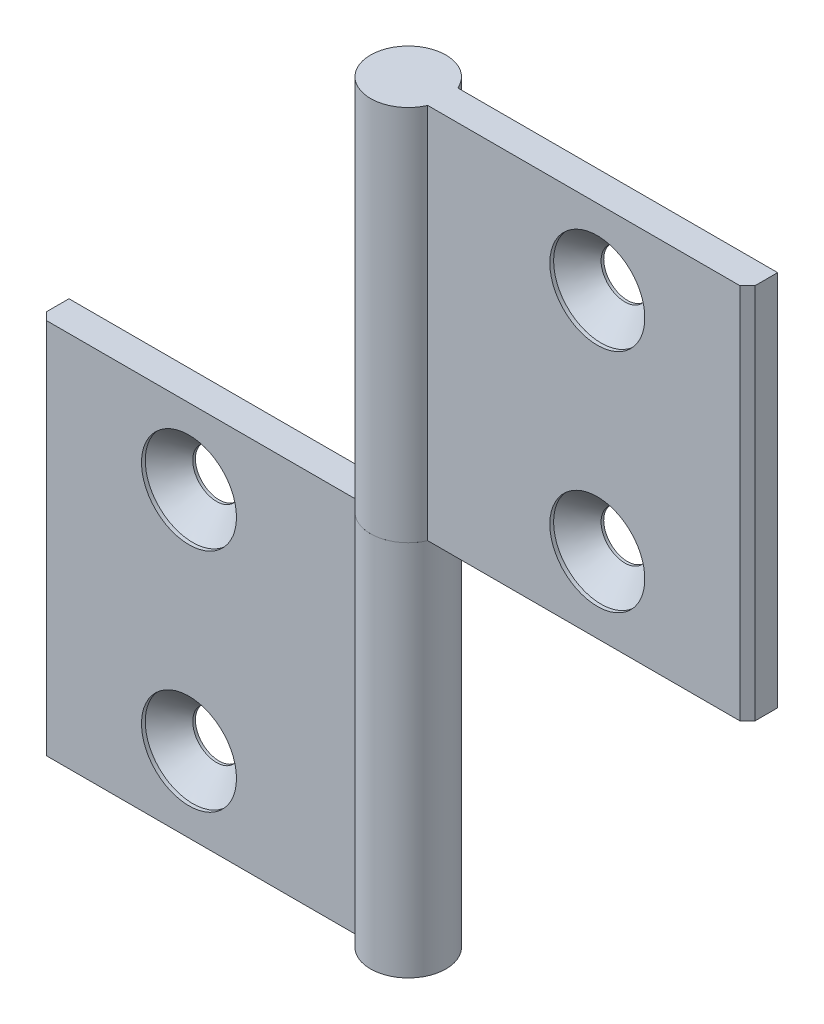
from build123d import *

# Parameters (mm, degrees)
EXTRUDE_1_DEPTH            = 25
HOLE_WIZARD_M61_AT_2_COUNT = 2
HOLE_WIZARD_M61_AT_2_PITCH = 30
PATTERN_CIRCULAR_1_COUNT   = 2


with BuildPart() as part:
    # Эскиз1 → Бобышка-Вытянуть1 (new body, symmetric)
    with BuildSketch(Plane(origin=(0, 0, 0), x_dir=(1, 0, 0), z_dir=(0, 1, 0))):
        with BuildLine():
            Line((-4.582575695, 2), (-47, 2))
            Line((-47, 2), (-47, -1))
            Line((-47, -1), (-46, -2))
            Line((-46, -2), (-4.582575695, -2))
            ThreePointArc((-4.582575695, -2), (5, 0), (-4.582575695, 2))
        make_face()
    extrude(amount=EXTRUDE_1_DEPTH, both=True)

    # Эскиз6 → Зенковка для винта с полупотайной головкой M61 (revolve, cut)
    with BuildSketch(Plane(origin=(-27.082575695, 15, 2), x_dir=(0, -1, 0), z_dir=(1, 0, 0))):
        Polygon((0, 0), (0, 7), (3.15, 7), (3.15, 3.65), (6.3, 0.5), (6.3, 0), align=None)
    hole_wizard_m61 = revolve(axis=Axis((-27.082575695, 15, 8.35), (0, 0, -1)), mode=Mode.SUBTRACT)

    # Зенковка для винта с полупотайной головкой M61 at 2: Зенковка для винта с полупотайной головкой M61 ×2
    with Locations(*[(0, -i * HOLE_WIZARD_M61_AT_2_PITCH, 0) for i in range(1, HOLE_WIZARD_M61_AT_2_COUNT)]):
        add(hole_wizard_m61, mode=Mode.SUBTRACT)


with BuildPart() as pattern_circular_1_1:
    # Круговой массив1: pattern copy
    add(part.part.rotate(Axis((0, 25, 0), (0, 0, 1)), 1 * 360 / PATTERN_CIRCULAR_1_COUNT))


solid = Compound([part.part, pattern_circular_1_1.part])
